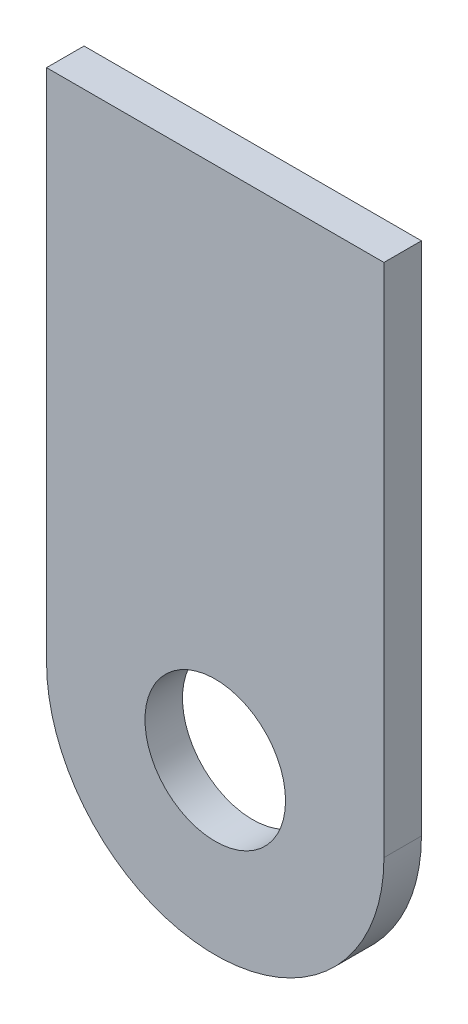
from build123d import *

# Parameters (mm, degrees)
SKETCH1_R           = 4.7625
BOSS_EXTRUDE1_DEPTH = 2.54


with BuildPart() as part:
    # Sketch1 → Boss-Extrude1 (new body)
    with BuildSketch(Plane.XY):
        with BuildLine():
            ThreePointArc((-11.43, 0), (0, -11.43), (11.43, 0))
            Line((11.43, 0), (11.43, 34.925))
            Line((11.43, 34.925), (-11.43, 34.925))
            Line((-11.43, 34.925), (-11.43, 0))
        make_face()
        Circle(SKETCH1_R, mode=Mode.SUBTRACT)
    extrude(amount=BOSS_EXTRUDE1_DEPTH)


solid = part.part
